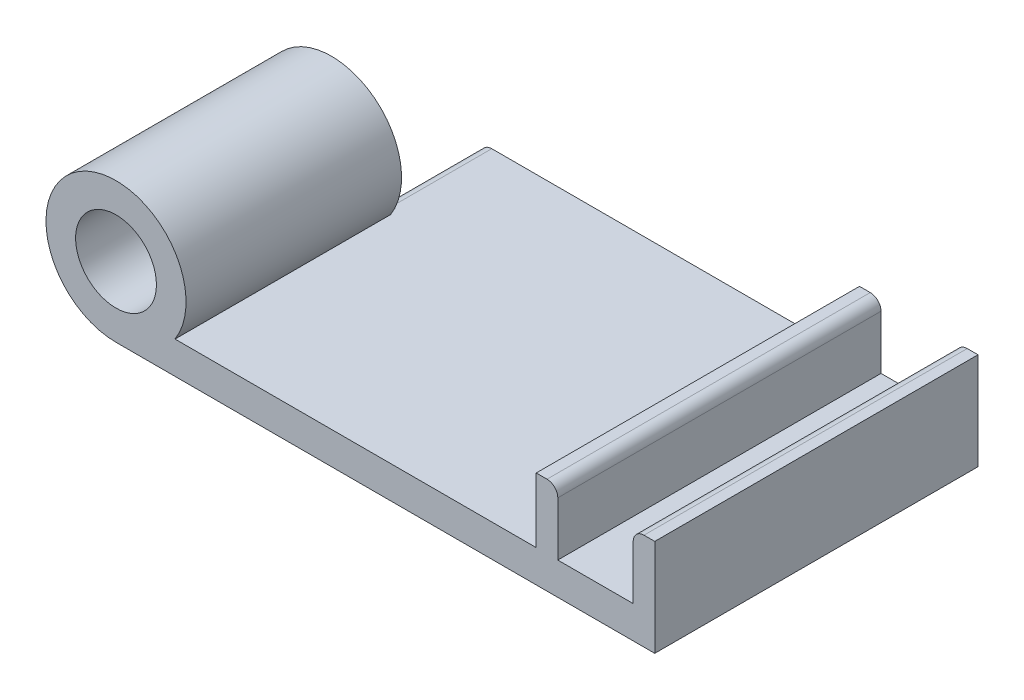
from build123d import *

# Parameters (mm, degrees)
BOSS_EXTRUDE1_DEPTH = 30
SKETCH3_R           = 6.5
SKETCH3_R_2         = 3.75
BOSS_EXTRUDE2_DEPTH = 20
SKETCH4_W           = 3.872983346
SKETCH4_H           = 3
CUT_EXTRUDE1_DEPTH  = 20
FILLET1_R           = 1


with BuildPart() as part:
    # Sketch1 → Boss-Extrude1 (new body)
    with BuildSketch(Plane.XY):
        Polygon((-25, -1.5), (25, -1.5), (25, 1.5), (25, 7.5), (23, 7.5), (23, 1.5), (16, 1.5), (16, 7.5), (14, 7.5), (14, 1.5), (-21.127016654, 1.5), align=None)
    extrude(amount=BOSS_EXTRUDE1_DEPTH)

    # Sketch3 → Boss-Extrude2 (add)
    with BuildSketch(Plane.XY.offset(30)):
        with Locations((-25, 5)):
            Circle(SKETCH3_R)
        with Locations((-25, 5)):
            Circle(SKETCH3_R_2, mode=Mode.SUBTRACT)
    extrude(amount=-BOSS_EXTRUDE2_DEPTH)

    # Sketch4 → Cut-Extrude1 (cut)
    with BuildSketch(Plane(origin=(0, 0, 10), x_dir=(-1, 0, 0), z_dir=(0, 0, -1))):
        with Locations((23.063508327, 0)):
            Rectangle(SKETCH4_W, SKETCH4_H)
    extrude(amount=CUT_EXTRUDE1_DEPTH, mode=Mode.SUBTRACT)

    # Fillet1
    fillet1_edges = [part.edges().sort_by_distance(p)[0] for p in [
        (16, 7.5, 15),
        (23, 7.5, 15),
        (-21.127016654, 1.5, 5),
    ]]
    fillet(fillet1_edges, radius=FILLET1_R)


solid = part.part
